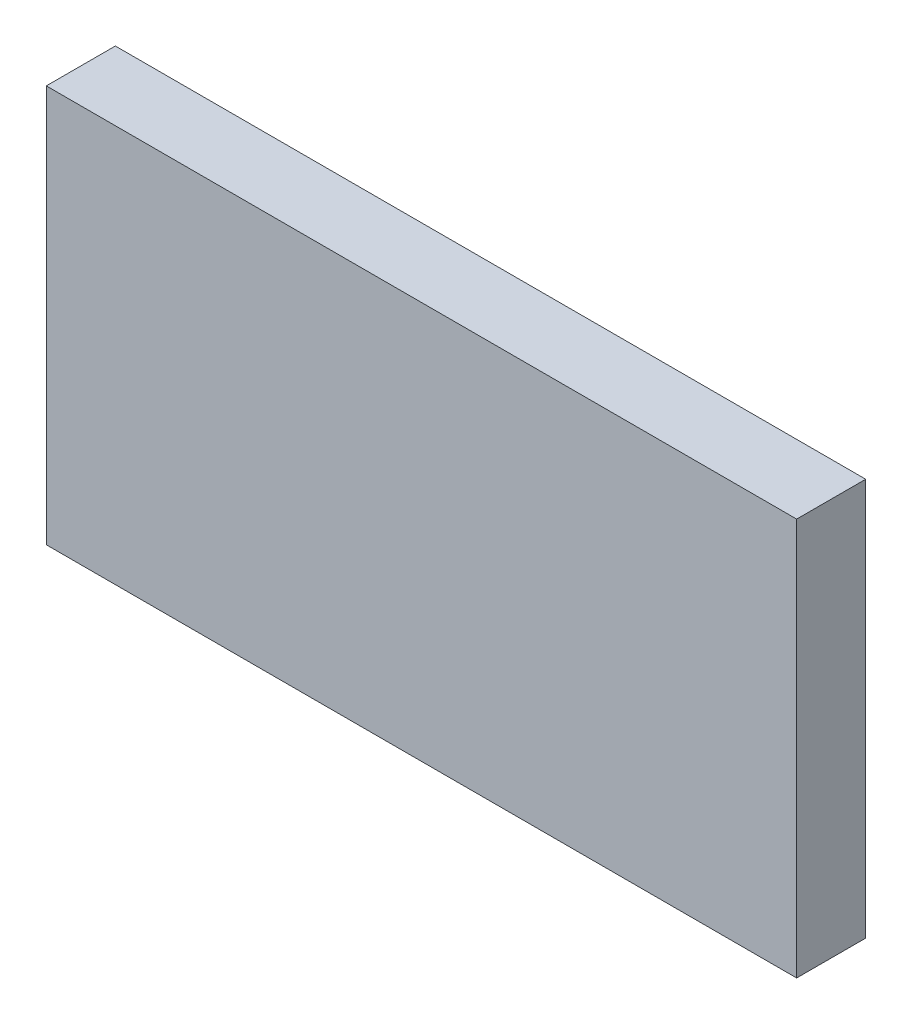
from build123d import *

# Parameters (mm, degrees)
SKETCH_1_W      = 108.668307982
SKETCH_1_H      = 57.557142858
EXTRUDE_1_DEPTH = 10


with BuildPart() as part:
    # 草圖1 → 填料-伸長1 (new body)
    with BuildSketch(Plane.XY):
        Rectangle(SKETCH_1_W, SKETCH_1_H)
    extrude(amount=EXTRUDE_1_DEPTH)


solid = part.part
